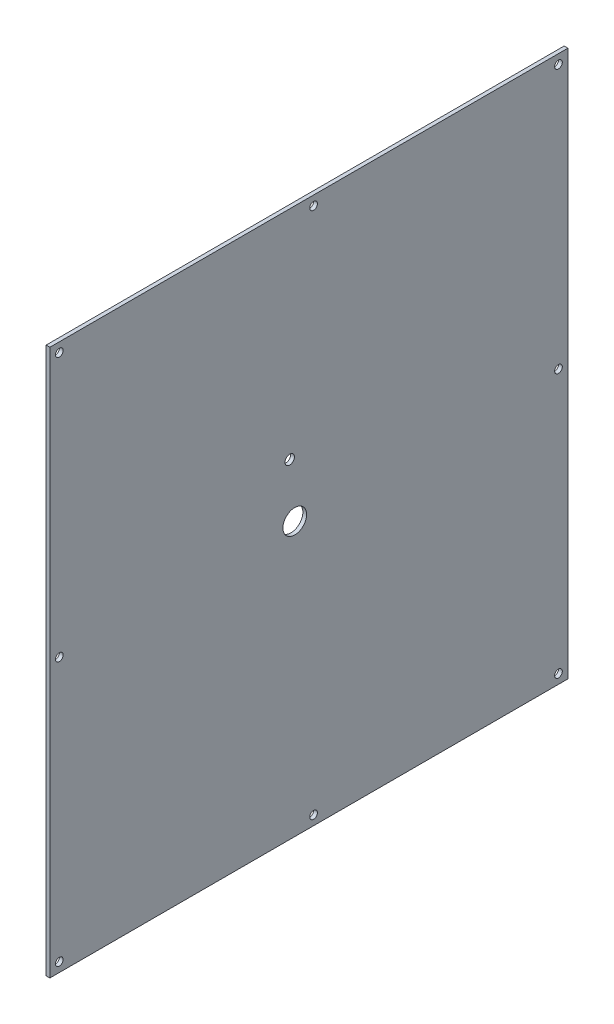
from build123d import *

# Parameters (mm, degrees)
SKETCH1_W                  = 368.3
SKETCH1_H                  = 368.3
BOSS_EXTRUDE1_DEPTH        = 2.54
F_6_0_204_DIAMETER_HOLE1_D = 5.1816
SKETCH3_W                  = 19.05
SKETCH3_H                  = 368.3
CUT_EXTRUDE1_DEPTH         = 2.54
SKETCH4_R                  = 8
CUT_EXTRUDE2_DEPTH         = 3.54
SKETCH5_R                  = 3.175
CUT_EXTRUDE3_DEPTH         = 2.54


with BuildPart() as part:
    # Sketch1 → Boss-Extrude1 (new body)
    with BuildSketch(Plane(origin=(0, 0, 0), x_dir=(0, 0, -1), z_dir=(1, 0, 0))):
        with Locations((184.15, 184.15)):
            Rectangle(SKETCH1_W, SKETCH1_H)
    extrude(amount=BOSS_EXTRUDE1_DEPTH)

    # #6 (0.204) Diameter Hole1 (through all)
    with Locations(Plane(origin=(2.54, 361.95, -361.95), x_dir=(0, 0, 1), z_dir=(1, 0, 0))):
        with Locations((0, 0), (0, 355.6), (336.55, 355.6), (336.55, 0), (336.55, 177.8), (0, 177.8), (165.1, 355.6), (165.1, 0)):
            Hole(F_6_0_204_DIAMETER_HOLE1_D / 2)

    # Sketch3 → Cut-Extrude1 (cut)
    with BuildSketch(Plane.ZY):
        with Locations((-9.525, 184.15)):
            Rectangle(SKETCH3_W, SKETCH3_H)
    extrude(amount=-CUT_EXTRUDE1_DEPTH, mode=Mode.SUBTRACT)

    # Sketch4 → Cut-Extrude2 (cut, through all)
    with BuildSketch(Plane.ZY):
        with Locations((-184.15, 184.15)):
            Circle(SKETCH4_R)
    extrude(amount=-CUT_EXTRUDE2_DEPTH, mode=Mode.SUBTRACT)

    # Sketch5 → Cut-Extrude3 (cut)
    with BuildSketch(Plane.ZY):
        with Locations((-180.737580342, 221.844041513)):
            Circle(SKETCH5_R)
    extrude(amount=-CUT_EXTRUDE3_DEPTH, mode=Mode.SUBTRACT)


solid = part.part
